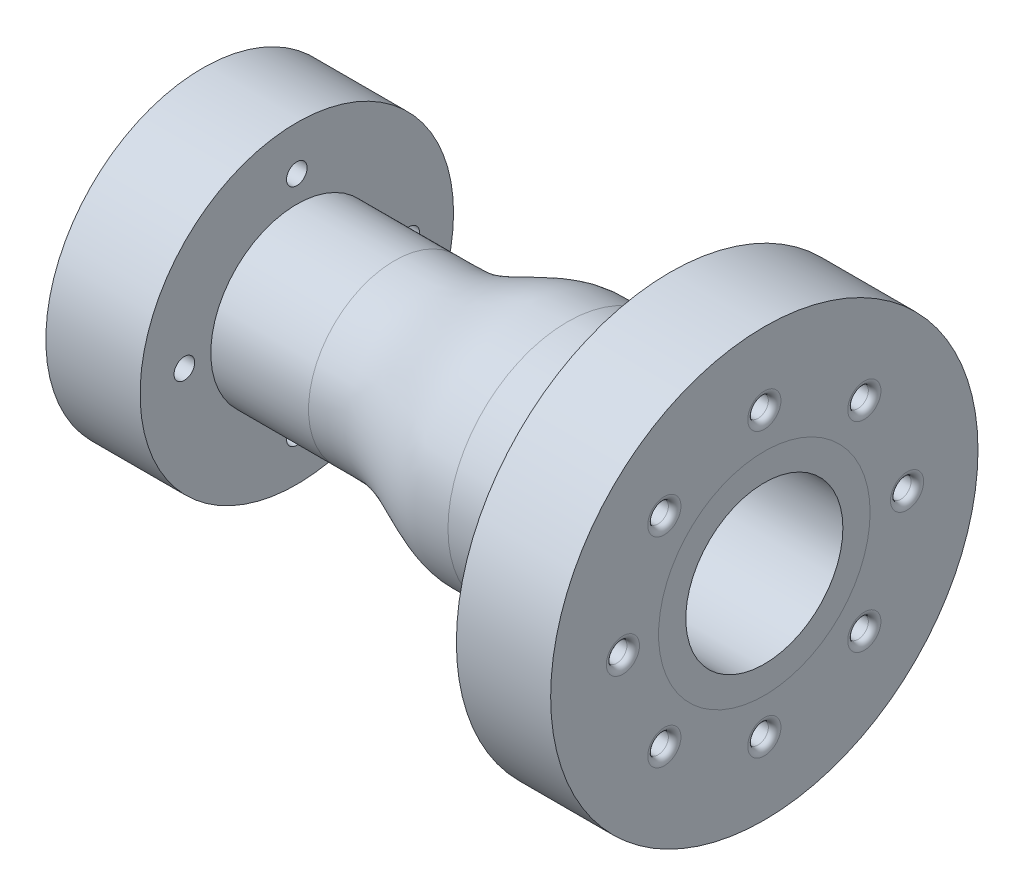
from build123d import *

# Parameters (mm, degrees)
F_5_8_CLEARANCE_HOLE1_D                             = 16.66748
F_5_8_CLEARANCE_HOLE1_DEPTH                         = 76.2
CSK_FOR_5_8_FLAT_HEAD_MACHINE_SCREW_100_D           = 16.66748
CSK_FOR_5_8_FLAT_HEAD_MACHINE_SCREW_100_DEPTH       = 76.2
CSK_FOR_5_8_FLAT_HEAD_MACHINE_SCREW_100_CSINK_D     = 32.3088
CSK_FOR_5_8_FLAT_HEAD_MACHINE_SCREW_100_CSINK_ANGLE = 100
FILLET1_R                                           = 5.08
FILLET2_R                                           = 5.08


with BuildPart() as part:
    # Sketch2 → Revolve1 (revolve)
    with BuildSketch(Plane.XY):
        with BuildLine():
            Line((397.9, 63.5), (397.9, 172.72))
            Line((397.9, 172.72), (321.7, 172.72))
            Line((321.7, 172.72), (321.7, 96.52))
            Line((321.7, 96.52), (238.7, 96.52))
            add(Edge.make_bspline(
                [(238.7, 96.52), (235.554162963, 96.52), (231.867635167, 96.520000854), (227.492955565, 96.519999574), (225.723422181, 96.520001904), (223.806427909, 96.519993991), (222.03689386, 96.520026856), (220.119901847, 96.519915241), (218.350358415, 96.520378787), (216.436180482, 96.518806814), (214.671251811, 96.525309284), (212.761120781, 96.469250093), (210.997970421, 96.364395267), (209.088061418, 96.194111756), (207.325068085, 95.986203736), (205.415339805, 95.708078479), (203.652528826, 95.403977645), (201.742980231, 95.02555544), (199.980349522, 94.632582243), (198.070973132, 94.162089846), (196.308510241, 93.688137455), (194.399291637, 93.134422106), (192.636978054, 92.587935066), (190.727898375, 91.960424077), (188.965712472, 91.350359442), (187.056750607, 90.659012211), (185.294669761, 89.994791139), (183.385803915, 89.250041466), (181.623805854, 88.541491878), (179.715014471, 87.754180902), (177.95307795, 87.011471767), (176.044340155, 86.192772243), (173.595279183, 85.127420353), (170.462272843, 83.743083739), (167.476201028, 82.415649714), (165.024786727, 81.331954435), (163.259291454, 80.556891201), (161.346657228, 79.726362453), (159.58112861, 78.970482115), (157.668449277, 78.166503816), (155.902867536, 77.440400295), (153.990122343, 76.674333295), (152.22446654, 75.988364429), (150.311633974, 75.27127071), (148.545882008, 74.635481527), (146.632940071, 73.97804432), (144.867069113, 73.402097288), (142.420307435, 72.650641631), (139.969078636, 71.968414381), (137.508584813, 71.37061928), (135.595192141, 70.951445026), (133.828840435, 70.608301664), (131.915268777, 70.28643942), (130.148732425, 70.036858101), (128.234978669, 69.820228423), (126.468267149, 69.671150711), (124.789582716, 69.579978245), (123.443760708, 69.539459525), (122.420535806, 69.531528206), (121.677966993, 69.532649541), (120.601758891, 69.532332583), (119.202172332, 69.532550669), (117.285177742, 69.532484277), (115.515644452, 69.532503827), (110.600274055, 69.532491757), (105.144212964, 69.532501185), (100.228842592, 69.532500252), (98.999999999, 69.532500252)],
                knots=[0, 0, 0, 0, 0.065409505, 0.076651764, 0.090960094, 0.102202352, 0.116510682, 0.12775294, 0.14206127, 0.153303528, 0.167554008, 0.178755429, 0.193030915, 0.204271905, 0.218620642, 0.229935227, 0.24439542, 0.255809505, 0.270408809, 0.281939941, 0.296695409, 0.308352907, 0.323271342, 0.335056718, 0.350135378, 0.362042998, 0.377270556, 0.389288475, 0.404646168, 0.416757099, 0.432220021, 0.44440238, 0.459940864, 0.487750951, 0.51562065, 0.52788688, 0.543480107, 0.55571106, 0.571242545, 0.583412274, 0.598850533, 0.610935794, 0.626253518, 0.638234915, 0.653410393, 0.66527347, 0.680291945, 0.692028204, 0.718490902, 0.733184872, 0.744670204, 0.75921598, 0.770592966, 0.785013865, 0.796305044, 0.810635098, 0.821871343, 0.831256632, 0.838627865, 0.843146285, 0.846696472, 0.861004801, 0.87224706, 0.886555389, 0.897797648, 0.974449412, 1, 1, 1, 1], degree=3, weights=[0.576132148, 0.576132148, 0.576132148, 0.576132148, 0.576132148, 0.576132148, 0.576132148, 0.576132148, 0.576132148, 0.576132148, 0.576132148, 0.576132148, 0.576132148, 0.576132148, 0.576132148, 0.576132148, 0.576132148, 0.576132148, 0.576132148, 0.576132148, 0.576132148, 0.576132148, 0.576132148, 0.576132148, 0.576132148, 0.576132148, 0.576132148, 0.576132148, 0.576132148, 0.576132148, 0.576132148, 0.576132148, 0.576132148, 0.576132148, 0.576132148, 0.576132148, 0.576132148, 0.576132148, 0.576132148, 0.576132148, 0.576132148, 0.576132148, 0.576132148, 0.576132148, 0.576132148, 0.576132148, 0.576132148, 0.576132148, 0.576132148, 0.576132148, 0.576132148, 0.576132148, 0.576132148, 0.576132148, 0.576132148, 0.576132148, 0.576132148, 0.576132148, 0.576132148, 0.576132148, 0.576132148, 0.576132148, 0.576132148, 0.576132148, 0.576132148, 0.576132148, 0.576132148, 0.576132148]))
            Line((98.999999999, 69.532500252), (20, 69.532500252))
            Line((20, 69.532500252), (20, 126.682500788))
            Line((20, 126.682500788), (-56.2, 126.682500788))
            Line((-56.2, 126.682500788), (-56.2, 36.512500252))
            Line((-56.2, 36.512500252), (98.999999999, 36.512500252))
            add(Edge.make_bspline(
                [(238.700000003, 63.5), (237.197046347, 63.5), (234.191102817, 63.500001102), (230.433854496, 63.4999983), (227.427706296, 63.500003237), (225.173865058, 63.499988149), (222.917803457, 63.50003916), (221.042945443, 63.499925019), (219.530442863, 63.500065616), (218.415469051, 63.500274875), (217.314204647, 63.499196223), (216.043652917, 63.501004921), (215.185961816, 63.500492351), (214.771405113, 63.493279052), (214.252526353, 63.475397551), (213.557944606, 63.437719421), (212.671955105, 63.365919575), (211.171969603, 63.191393403), (209.16325102, 62.85805214), (206.51804476, 62.257683474), (203.646999002, 61.45108291), (200.561516635, 60.440925391), (196.179509039, 58.836675172), (190.229936587, 56.387089311), (182.372449203, 52.902698484), (173.744930391, 49.071084114), (165.800813574, 45.78037874), (158.892971077, 43.243828352), (153.408855442, 41.441256442), (147.598282729, 39.799102649), (141.448772399, 38.390555181), (136.042331475, 37.481212687), (131.570176876, 36.957907859), (128.709477108, 36.724058743), (126.402007952, 36.59980834), (124.96048965, 36.547914527), (123.738484125, 36.522666819), (122.884366988, 36.513769348), (122.221972387, 36.512085435), (121.791199415, 36.512386125), (121.454945133, 36.512626057), (120.987601277, 36.512442102), (120.226451203, 36.512415242), (119.286874933, 36.512499795), (118.163967218, 36.512520791), (116.659276737, 36.512481233), (114.781129764, 36.512509034), (112.526602378, 36.512495404), (110.272151814, 36.512496718), (107.266212904, 36.512496724), (103.508842845, 36.512500733), (100.502947689, 36.512500252), (98.999999999, 36.512500252)],
                knots=[0, 0, 0, 0, 0.03125, 0.0625, 0.078125, 0.09375, 0.109375, 0.125, 0.1328125, 0.140625, 0.1484375, 0.15625, 0.1640625, 0.171875, 0.1796875, 0.1875, 0.203125, 0.21875, 0.25, 0.28125, 0.3125, 0.34375, 0.375, 0.4375, 0.5, 0.5625, 0.625, 0.65625, 0.6875, 0.71875, 0.75, 0.78125, 0.796875, 0.8125, 0.8203125, 0.828125, 0.83203125, 0.8359375, 0.83984375, 0.841796875, 0.84375, 0.84765625, 0.8515625, 0.859375, 0.8671875, 0.875, 0.890625, 0.90625, 0.921875, 0.9375, 0.96875, 1, 1, 1, 1], degree=3))
            Line((238.700000003, 63.5), (397.9, 63.5))
        make_face()
    revolve(axis=Axis((341.7, 0, 0), (-1, 0, 0)))

    # 5/8 Clearance Hole1
    with Locations(Plane(origin=(-56.2, -86.94526051, 61.229912904), x_dir=(0, 0, 1), z_dir=(-1, 0, 0))):
        with Locations((-61.229912904, 177.798020209), (29.681467244, 86.94526051), (-61.229912904, -3.966119638), (-152.141293051, 86.94526051)):
            Hole(F_5_8_CLEARANCE_HOLE1_D / 2, depth=F_5_8_CLEARANCE_HOLE1_DEPTH)

    # CSK for 5_8 Flat Head Machine Screw _100
    with Locations(Plane(origin=(321.7, -86.94526051, 61.229912904), x_dir=(0, 0, 1), z_dir=(-1, 0, 0))):
        with Locations((-61.229912904, 201.24526051), (-176.596487394, 86.94526051), (-142.052217993, 167.767565599), (19.592392186, 167.767565599), (53.070087096, 86.94526051), (19.592392186, 6.12295542), (-61.229912904, -27.406492985), (-142.052217993, 6.12295542)):
            CounterSinkHole(CSK_FOR_5_8_FLAT_HEAD_MACHINE_SCREW_100_D / 2, CSK_FOR_5_8_FLAT_HEAD_MACHINE_SCREW_100_CSINK_D / 2, depth=CSK_FOR_5_8_FLAT_HEAD_MACHINE_SCREW_100_DEPTH, counter_sink_angle=CSK_FOR_5_8_FLAT_HEAD_MACHINE_SCREW_100_CSINK_ANGLE)

    # Fillet1
    fillet1_edges = [part.edges().sort_by_distance(p)[0] for p in [
        (397.9, 114.3, 8.33374),
        (397.9, -80.82230509, -72.488565089),
        (397.9, -114.351753495, 8.33374),
        (397.9, -80.82230509, 89.15604509),
        (397.9, 0, 122.63374),
        (397.9, 80.822305089, 89.15604509),
        (397.9, 80.822305089, -72.488565089),
        (397.9, 0, -107.03283449),
    ]]
    fillet(fillet1_edges, radius=FILLET1_R)

    # Fillet2
    fillet2_edges = [part.edges().sort_by_distance(p)[0] for p in [
        (-56.2, 0, -82.577640147),
        (-56.2, -90.911380148, 8.33374),
        (-56.2, 0, 99.245120148),
        (-56.2, 90.852759699, 8.33374),
    ]]
    fillet(fillet2_edges, radius=FILLET2_R)


solid = part.part
